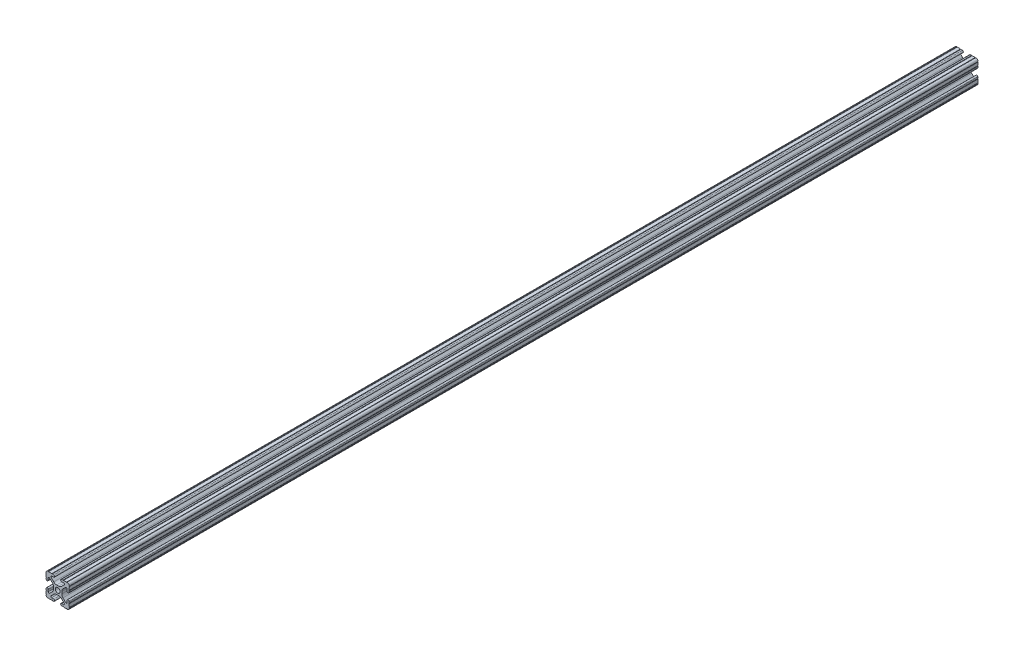
from build123d import *

# Parameters (mm, degrees)
SKETCH3_R      = 2.6035
EXTRUDE1_DEPTH = 495.3


with BuildPart() as part:
    # Sketch3 → Extrude1 (new body, symmetric)
    with BuildSketch(Plane.XY):
        with BuildLine():
            Line((-1.115277175, 4.5085), (1.115277175, 4.5085))
            ThreePointArc((1.115277175, 4.5085), (2.806584872, 4.844922018), (4.240406305, 5.80297087))
            Line((4.240406305, 5.80297087), (7.148423664, 8.710988229))
            ThreePointArc((7.148423664, 8.710988229), (7.349906316, 9.772227925), (6.436353897, 10.348636575))
            Line((6.436353897, 10.348636575), (4.381960454, 10.276895575))
            ThreePointArc((4.381960454, 10.276895575), (3.239173075, 11.342562046), (4.304839546, 12.485349424))
            Line((4.304839546, 12.485349424), (5.728246175, 12.535055879))
            ThreePointArc((5.728246175, 12.535055879), (6.054756855, 12.230579745), (6.35923299, 12.557090424))
            Line((6.35923299, 12.557090424), (9.782092278, 12.676619304))
            ThreePointArc((9.782092278, 12.676619304), (10.108602958, 12.37214317), (10.413079092, 12.69865385))
            ThreePointArc((10.413079092, 12.69865385), (12.052764565, 12.052764565), (12.69865385, 10.413079092))
            ThreePointArc((12.69865385, 10.413079092), (12.37214317, 10.108602958), (12.676619304, 9.782092278))
            Line((12.676619304, 9.782092278), (12.557090424, 6.35923299))
            ThreePointArc((12.557090424, 6.35923299), (12.230579745, 6.054756855), (12.535055879, 5.728246175))
            Line((12.535055879, 5.728246175), (12.485349424, 4.304839546))
            ThreePointArc((12.485349424, 4.304839546), (11.342562046, 3.239173075), (10.276895575, 4.381960454))
            Line((10.276895575, 4.381960454), (10.348636575, 6.436353897))
            ThreePointArc((10.348636575, 6.436353897), (9.772227925, 7.349906316), (8.710988229, 7.148423664))
            Line((8.710988229, 7.148423664), (5.80297087, 4.240406305))
            ThreePointArc((5.80297087, 4.240406305), (4.844922018, 2.806584872), (4.5085, 1.115277175))
            Line((4.5085, 1.115277175), (4.5085, -1.115277175))
            ThreePointArc((4.5085, -1.115277175), (4.844922018, -2.806584872), (5.80297087, -4.240406305))
            Line((5.80297087, -4.240406305), (8.710988229, -7.148423664))
            ThreePointArc((8.710988229, -7.148423664), (9.772227925, -7.349906316), (10.348636575, -6.436353897))
            Line((10.348636575, -6.436353897), (10.276895575, -4.381960454))
            ThreePointArc((10.276895575, -4.381960454), (11.342562046, -3.239173075), (12.485349424, -4.304839546))
            Line((12.485349424, -4.304839546), (12.535055879, -5.728246175))
            ThreePointArc((12.535055879, -5.728246175), (12.230579745, -6.054756855), (12.557090424, -6.35923299))
            Line((12.557090424, -6.35923299), (12.676619304, -9.782092278))
            ThreePointArc((12.676619304, -9.782092278), (12.37214317, -10.108602958), (12.69865385, -10.413079092))
            ThreePointArc((12.69865385, -10.413079092), (12.052764565, -12.052764565), (10.413079092, -12.69865385))
            ThreePointArc((10.413079092, -12.69865385), (10.108602958, -12.37214317), (9.782092278, -12.676619304))
            Line((9.782092278, -12.676619304), (6.35923299, -12.557090424))
            ThreePointArc((6.35923299, -12.557090424), (6.054756855, -12.230579745), (5.728246175, -12.535055879))
            Line((5.728246175, -12.535055879), (4.304839546, -12.485349424))
            ThreePointArc((4.304839546, -12.485349424), (3.239173075, -11.342562046), (4.381960454, -10.276895575))
            Line((4.381960454, -10.276895575), (6.436353897, -10.348636575))
            ThreePointArc((6.436353897, -10.348636575), (7.349906316, -9.772227925), (7.148423664, -8.710988229))
            Line((7.148423664, -8.710988229), (4.240406305, -5.80297087))
            ThreePointArc((4.240406305, -5.80297087), (2.806584872, -4.844922018), (1.115277175, -4.5085))
            Line((1.115277175, -4.5085), (-1.115277175, -4.5085))
            ThreePointArc((-1.115277175, -4.5085), (-2.806584872, -4.844922018), (-4.240406305, -5.80297087))
            Line((-4.240406305, -5.80297087), (-7.148423664, -8.710988229))
            ThreePointArc((-7.148423664, -8.710988229), (-7.349906316, -9.772227925), (-6.436353897, -10.348636575))
            Line((-6.436353897, -10.348636575), (-4.381960454, -10.276895575))
            ThreePointArc((-4.381960454, -10.276895575), (-3.239173075, -11.342562046), (-4.304839546, -12.485349424))
            Line((-4.304839546, -12.485349424), (-5.728246175, -12.535055879))
            ThreePointArc((-5.728246175, -12.535055879), (-6.054756855, -12.230579745), (-6.35923299, -12.557090424))
            Line((-6.35923299, -12.557090424), (-9.782092278, -12.676619304))
            ThreePointArc((-9.782092278, -12.676619304), (-10.108602958, -12.37214317), (-10.413079092, -12.69865385))
            ThreePointArc((-10.413079092, -12.69865385), (-12.052764565, -12.052764565), (-12.69865385, -10.413079092))
            ThreePointArc((-12.69865385, -10.413079092), (-12.37214317, -10.108602958), (-12.676619304, -9.782092278))
            Line((-12.676619304, -9.782092278), (-12.557090424, -6.35923299))
            ThreePointArc((-12.557090424, -6.35923299), (-12.230579745, -6.054756855), (-12.535055879, -5.728246175))
            Line((-12.535055879, -5.728246175), (-12.485349424, -4.304839546))
            ThreePointArc((-12.485349424, -4.304839546), (-11.342562046, -3.239173075), (-10.276895575, -4.381960454))
            Line((-10.276895575, -4.381960454), (-10.348636575, -6.436353897))
            ThreePointArc((-10.348636575, -6.436353897), (-9.772227925, -7.349906316), (-8.710988229, -7.148423664))
            Line((-8.710988229, -7.148423664), (-5.80297087, -4.240406305))
            ThreePointArc((-5.80297087, -4.240406305), (-4.844922018, -2.806584872), (-4.5085, -1.115277175))
            Line((-4.5085, -1.115277175), (-4.5085, 1.115277175))
            ThreePointArc((-4.5085, 1.115277175), (-4.844922018, 2.806584872), (-5.80297087, 4.240406305))
            Line((-5.80297087, 4.240406305), (-8.710988229, 7.148423664))
            ThreePointArc((-8.710988229, 7.148423664), (-9.772227925, 7.349906316), (-10.348636575, 6.436353897))
            Line((-10.348636575, 6.436353897), (-10.276895575, 4.381960454))
            ThreePointArc((-10.276895575, 4.381960454), (-11.342562046, 3.239173075), (-12.485349424, 4.304839546))
            Line((-12.485349424, 4.304839546), (-12.535055879, 5.728246175))
            ThreePointArc((-12.535055879, 5.728246175), (-12.230579745, 6.054756855), (-12.557090424, 6.35923299))
            Line((-12.557090424, 6.35923299), (-12.676619304, 9.782092278))
            ThreePointArc((-12.676619304, 9.782092278), (-12.37214317, 10.108602958), (-12.69865385, 10.413079092))
            ThreePointArc((-12.69865385, 10.413079092), (-12.052764565, 12.052764565), (-10.413079092, 12.69865385))
            ThreePointArc((-10.413079092, 12.69865385), (-10.108602958, 12.37214317), (-9.782092278, 12.676619304))
            Line((-9.782092278, 12.676619304), (-6.35923299, 12.557090424))
            ThreePointArc((-6.35923299, 12.557090424), (-6.054756855, 12.230579745), (-5.728246175, 12.535055879))
            Line((-5.728246175, 12.535055879), (-4.304839546, 12.485349424))
            ThreePointArc((-4.304839546, 12.485349424), (-3.239173075, 11.342562046), (-4.381960454, 10.276895575))
            Line((-4.381960454, 10.276895575), (-6.436353897, 10.348636575))
            ThreePointArc((-6.436353897, 10.348636575), (-7.349906316, 9.772227925), (-7.148423664, 8.710988229))
            Line((-7.148423664, 8.710988229), (-4.240406305, 5.80297087))
            ThreePointArc((-4.240406305, 5.80297087), (-2.806584872, 4.844922018), (-1.115277175, 4.5085))
        make_face()
        Circle(SKETCH3_R, mode=Mode.SUBTRACT)
    extrude(amount=EXTRUDE1_DEPTH, both=True)


solid = part.part
